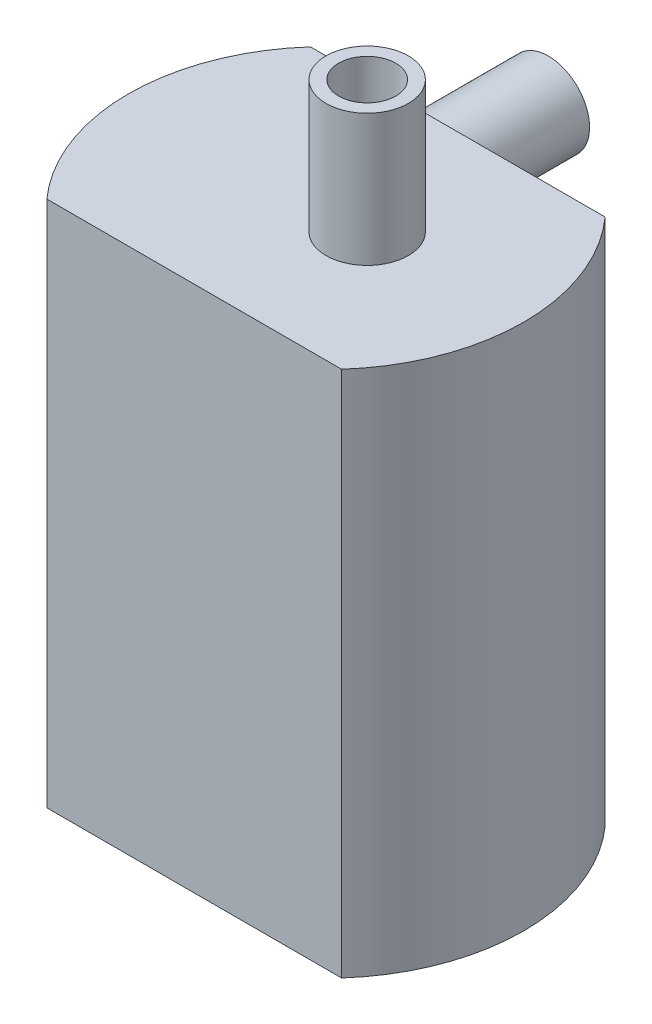
from build123d import *

# Parameters (mm, degrees)
BOSS_EXTRUDE2_DEPTH = 50.8
SKETCH2_R           = 3.96875
SKETCH2_R_2         = 2.75
BOSS_EXTRUDE3_DEPTH = 12.7
SKETCH3_R           = 3.96875
SKETCH3_R_2         = 2.75
BOSS_EXTRUDE4_DEPTH = 12.7


with BuildPart() as part:
    # Sketch1 → Boss-Extrude2 (new body)
    with BuildSketch(Plane(origin=(0, 0, 0), x_dir=(1, 0, 0), z_dir=(0, 1, 0))):
        with BuildLine():
            Line((14.199031657, 12.7), (-14.199031657, 12.7))
            ThreePointArc((-14.199031657, 12.7), (-19.05, 0), (-14.199031657, -12.7))
            Line((-14.199031657, -12.7), (14.199031657, -12.7))
            ThreePointArc((14.199031657, -12.7), (17.795983438, -6.79746081), (19.05, 0))
            ThreePointArc((19.05, 0), (17.795983438, 6.79746081), (14.199031657, 12.7))
        make_face()
    extrude(amount=BOSS_EXTRUDE2_DEPTH)

    # Sketch2 → Boss-Extrude3 (add)
    with BuildSketch(Plane(origin=(0, 50.8, 0), x_dir=(1, 0, 0), z_dir=(0, 1, 0))):
        with Locations((3.96875, 0)):
            Circle(SKETCH2_R)
        with Locations((3.96875, 0)):
            Circle(SKETCH2_R_2, mode=Mode.SUBTRACT)
    extrude(amount=BOSS_EXTRUDE3_DEPTH)

    # Sketch3 → Boss-Extrude4 (add)
    with BuildSketch(Plane(origin=(0, 0, -12.7), x_dir=(-1, 0, 0), z_dir=(0, 0, -1))):
        with Locations((3.96875, 44.83125)):
            Circle(SKETCH3_R)
        with Locations((3.96875, 44.83125)):
            Circle(SKETCH3_R_2, mode=Mode.SUBTRACT)
    extrude(amount=BOSS_EXTRUDE4_DEPTH)


solid = part.part
